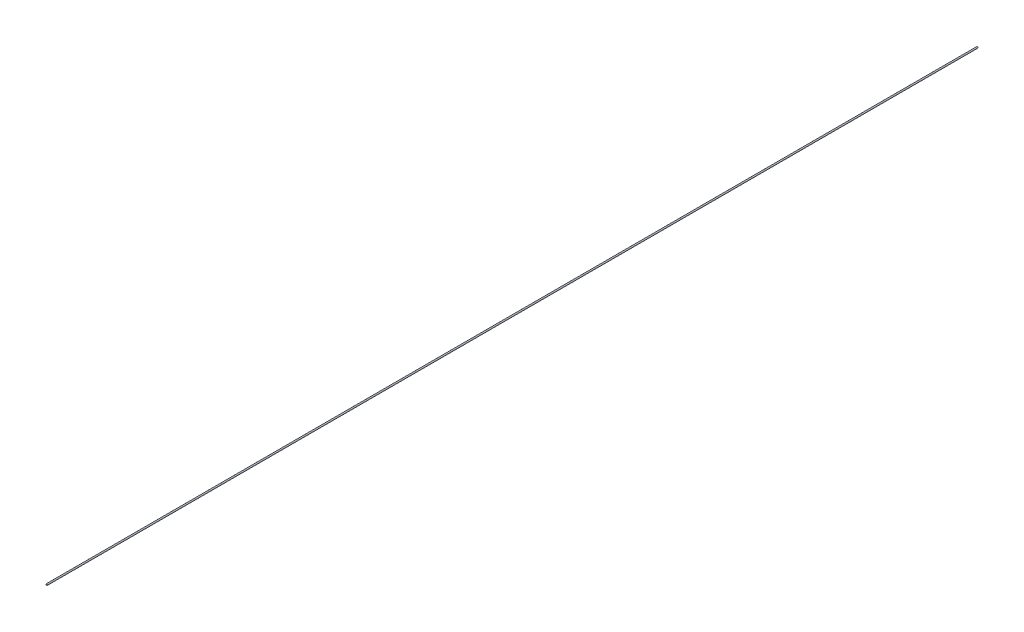
from build123d import *

# Parameters (mm, degrees)
SKETCH2_R           = 1
BOSS_EXTRUDE1_DEPTH = 1357


with BuildPart() as part:
    # Sketch2 → Boss-Extrude1 (new body)
    with BuildSketch(Plane.XY):
        with Locations((-304.504955965, -230.173862593)):
            Circle(SKETCH2_R)
    extrude(amount=BOSS_EXTRUDE1_DEPTH)


solid = part.part
